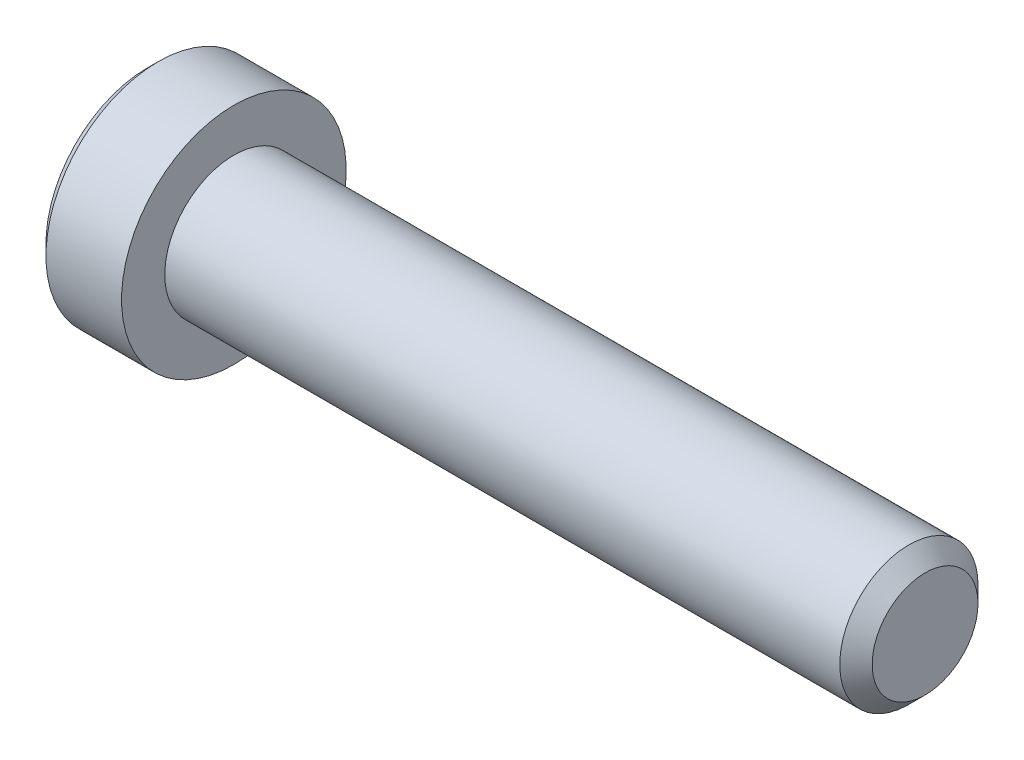
from build123d import *

# Parameters (mm, degrees)
SKETCH2_R           = 4
BOSS_EXTRUDE1_DEPTH = 22
CHAMFER1_SIZE       = 0.9375
CUT_EXTRUDE1_DEPTH  = 3.95


with BuildPart() as part:
    # Sketch2 → Boss-Extrude1 (new body)
    with BuildSketch(Plane(origin=(20, 0, 0), x_dir=(0, 0, -1), z_dir=(1, 0, 0))):
        Circle(SKETCH2_R)
    extrude(amount=-BOSS_EXTRUDE1_DEPTH)

    # Chamfer1
    chamfer1_edges = [part.edges().sort_by_distance(p)[0] for p in [
        (20, 0, 4),
    ]]
    chamfer(chamfer1_edges, length=CHAMFER1_SIZE)

    # Sketch10 → Revolve2 (revolve)
    with BuildSketch(Plane.XY, mode=Mode.PRIVATE) as revolve2_sk:
        Polygon((0.309401077, 0), (-2, 4), (-20, 4), (-20, 0), align=None)
    revolve(revolve2_sk.sketch.rotate(Axis((-20, 0, 0), (1, 0, 0)), 270), axis=Axis((-20, 0, 0), (1, 0, 0)))

    # Sketch6 → Revolve1 (revolve)
    with BuildSketch(Plane.XY):
        Polygon((-24.375, 6.5), (-25, 5.875), (-25, 0), (-20, 0), (-20, 6.5), align=None)
    revolve(axis=Axis((-20, 0, 0), (-1, 0, 0)))

    # Sketch4 → Cut-Extrude1 (cut)
    with BuildSketch(Plane(origin=(-25, 0, 0), x_dir=(0, 0, -1), z_dir=(1, 0, 0))):
        Polygon((0, 2.886751346), (-2.5, 1.443375673), (-2.5, -1.443375673), (0, -2.886751346), (2.5, -1.443375673), (2.5, 1.443375673), align=None)
    extrude(amount=CUT_EXTRUDE1_DEPTH, mode=Mode.SUBTRACT)

    # Cut-Extrude2 cone 1 section (through the dimple's axis) → Cut-Extrude2 (revolve, cut)
    with BuildSketch(Plane(origin=(-25, 0, 0), x_dir=(0, 0, 1), z_dir=(0, 1, 0))):
        Polygon((0, 0), (2.886751346, 0), (0, 2.886751346), align=None)
    revolve(axis=Axis((-25, 0, 0), (1, 0, 0)), mode=Mode.SUBTRACT)


solid = part.part
